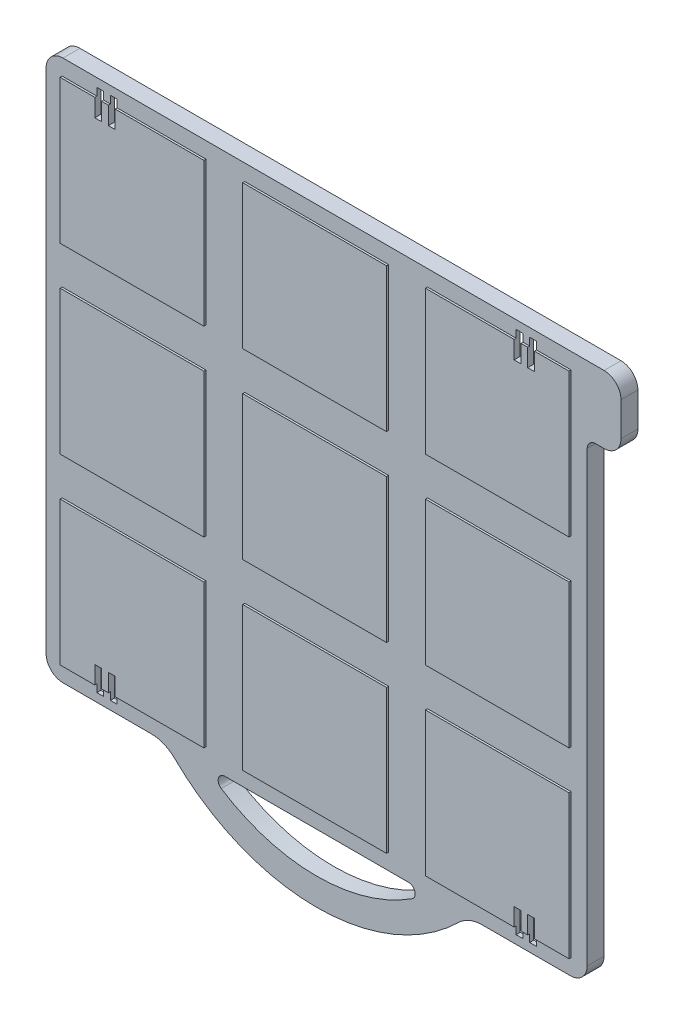
from build123d import *

# Parameters (mm, degrees)
BOSS_EXTRUDE1_DEPTH = 6.35
SHELL1_T            = -1.524
SKETCH2_W           = 53.975
SKETCH2_H           = 53.975
BOSS_EXTRUDE2_DEPTH = 0.762
SKETCH3_W           = 2.54
SKETCH3_H           = 9.525
CUT_EXTRUDE1_DEPTH  = 172.008977963
SKETCH4_R           = 6.2865
SKETCH4_R_2         = 4.7625
BOSS_EXTRUDE3_DEPTH = 4.826
RIB1_REACH          = 173.009
SKETCH5_WALLS_W     = 437.807455926
SKETCH5_WALLS_H     = 1.27
SKETCH5_WALLS_W_2   = 1.27
SKETCH5_WALLS_H_2   = 437.807455926


with BuildPart() as part:
    # Sketch1 → Boss-Extrude1 (new body)
    with BuildSketch(Plane.XY):
        with BuildLine():
            Line((101.6, 101.6), (107.95, 101.6))
            ThreePointArc((107.95, 101.6), (112.440128061, 99.740128061), (114.3, 95.25))
            Line((114.3, 95.25), (114.3, 82.55))
            ThreePointArc((114.3, 82.55), (112.440128061, 78.059871939), (107.95, 76.2))
            Line((107.95, 76.2), (104.775, 76.2))
            ThreePointArc((104.775, 76.2), (102.52993597, 75.27006403), (101.6, 73.025))
            Line((101.6, 73.025), (101.6, -95.25))
            ThreePointArc((101.6, -95.25), (99.740128061, -99.740128061), (95.25, -101.6))
            Line((95.25, -101.6), (62.217039467, -101.6))
            ThreePointArc((62.217039467, -101.6), (57.416890659, -102.542084733), (53.328890971, -105.228571429))
            ThreePointArc((53.328890971, -105.228571429), (0, -127), (-53.328890971, -105.228571429))
            ThreePointArc((-53.328890971, -105.228571429), (-57.416890659, -102.542084733), (-62.217039467, -101.6))
            Line((-62.217039467, -101.6), (-95.25, -101.6))
            ThreePointArc((-95.25, -101.6), (-99.740128061, -99.740128061), (-101.6, -95.25))
            Line((-101.6, -95.25), (-101.6, 95.25))
            ThreePointArc((-101.6, 95.25), (-99.740128061, 99.740128061), (-95.25, 101.6))
            Line((-95.25, 101.6), (101.6, 101.6))
        make_face()
        with BuildLine():
            Line((-34.454236314, -101.6), (34.454236314, -101.6))
            ThreePointArc((34.454236314, -101.6), (36.890518728, -103.42157951), (35.832405767, -106.2736))
            ThreePointArc((35.832405767, -106.2736), (0, -116.84), (-35.832405767, -106.2736))
            ThreePointArc((-35.832405767, -106.2736), (-36.890518728, -103.42157951), (-34.454236314, -101.6))
        make_face(mode=Mode.SUBTRACT)
    extrude(amount=BOSS_EXTRUDE1_DEPTH)

    # Shell1
    shell1_openings = [part.faces().sort_by_distance(p)[0] for p in [
        (0.794834734, -2.433656068, 0),
    ]]
    offset(amount=SHELL1_T, openings=shell1_openings, kind=Kind.INTERSECTION)

    # Sketch2 → Boss-Extrude2 (add)
    with BuildSketch(Plane.XY.offset(6.35)):
        with Locations((68.58, 0)):
            Rectangle(SKETCH2_W, SKETCH2_H)
        Rectangle(SKETCH2_W, SKETCH2_H)
        with Locations((68.58, 68.58)):
            Rectangle(SKETCH2_W, SKETCH2_H)
        with Locations((68.58, -68.58)):
            Rectangle(SKETCH2_W, SKETCH2_H)
        with Locations((0, -68.58)):
            Rectangle(SKETCH2_W, SKETCH2_H)
        with Locations((-68.58, -68.58)):
            Rectangle(SKETCH2_W, SKETCH2_H)
        with Locations((-68.58, 0)):
            Rectangle(SKETCH2_W, SKETCH2_H)
        with Locations((-68.58, 68.58)):
            Rectangle(SKETCH2_W, SKETCH2_H)
        with Locations((0, 68.58)):
            Rectangle(SKETCH2_W, SKETCH2_H)
    extrude(amount=BOSS_EXTRUDE2_DEPTH)

    # Sketch3 → Cut-Extrude1 (cut, through all)
    with BuildSketch(Plane.XY.offset(7.112)):
        with Locations((-81.28, 93.6625)):
            Rectangle(SKETCH3_W, SKETCH3_H)
        with Locations((-76.2, 93.6625)):
            Rectangle(SKETCH3_W, SKETCH3_H)
        with Locations((76.2, 93.6625)):
            Rectangle(SKETCH3_W, SKETCH3_H)
        with Locations((81.28, 93.6625)):
            Rectangle(SKETCH3_W, SKETCH3_H)
        with Locations((81.28, -93.6625)):
            Rectangle(SKETCH3_W, SKETCH3_H)
        with Locations((76.2, -93.6625)):
            Rectangle(SKETCH3_W, SKETCH3_H)
        with Locations((-76.2, -93.6625)):
            Rectangle(SKETCH3_W, SKETCH3_H)
        with Locations((-81.28, -93.6625)):
            Rectangle(SKETCH3_W, SKETCH3_H)
    extrude(amount=-CUT_EXTRUDE1_DEPTH, mode=Mode.SUBTRACT)

    # Sketch4 → Boss-Extrude3 (add)
    with BuildSketch(Plane(origin=(0, 0, 4.826), x_dir=(-1, 0, 0), z_dir=(0, 0, -1))):
        Circle(SKETCH4_R)
        Circle(SKETCH4_R_2, mode=Mode.SUBTRACT)
    extrude(amount=BOSS_EXTRUDE3_DEPTH)

    # Sketch5 walls → Rib1 (add, up to next)
    with BuildSketch(Plane(origin=(0, 0, 0), x_dir=(-1, 0, 0), z_dir=(0, 0, -1)), mode=Mode.PRIVATE) as rib1_sk1:
        with Locations((53.18125, 0)):
            Rectangle(SKETCH5_WALLS_W, SKETCH5_WALLS_H)
    rib1_tool1 = extrude(rib1_sk1.sketch, amount=-RIB1_REACH, mode=Mode.PRIVATE) - part.part
    # Sketch5 walls → Rib1 (add, up to next)
    with BuildSketch(Plane(origin=(0, 0, 0), x_dir=(-1, 0, 0), z_dir=(0, 0, -1)), mode=Mode.PRIVATE) as rib1_sk2:
        with Locations((-53.18125, 0)):
            Rectangle(SKETCH5_WALLS_W, SKETCH5_WALLS_H)
    rib1_tool2 = extrude(rib1_sk2.sketch, amount=-RIB1_REACH, mode=Mode.PRIVATE) - part.part
    # Sketch5 walls → Rib1 (add, up to next)
    with BuildSketch(Plane(origin=(0, 0, 0), x_dir=(-1, 0, 0), z_dir=(0, 0, -1)), mode=Mode.PRIVATE) as rib1_sk3:
        with Locations((0, -53.18125)):
            Rectangle(SKETCH5_WALLS_W_2, SKETCH5_WALLS_H_2)
    rib1_tool3 = extrude(rib1_sk3.sketch, amount=-RIB1_REACH, mode=Mode.PRIVATE) - part.part
    # Sketch5 walls → Rib1 (add, up to next)
    with BuildSketch(Plane(origin=(0, 0, 0), x_dir=(-1, 0, 0), z_dir=(0, 0, -1)), mode=Mode.PRIVATE) as rib1_sk4:
        with Locations((0, 53.18125)):
            Rectangle(SKETCH5_WALLS_W_2, SKETCH5_WALLS_H_2)
    rib1_tool4 = extrude(rib1_sk4.sketch, amount=-RIB1_REACH, mode=Mode.PRIVATE) - part.part
    # Sketch5 walls → Rib1 (add, up to next)
    with BuildSketch(Plane(origin=(0, 0, 0), x_dir=(-1, 0, 0), z_dir=(0, 0, -1)), mode=Mode.PRIVATE) as rib1_sk5:
        Polygon((-116.734475157, -117.632500769), (220.740224875, 219.842199263), (219.842199263, 220.740224875), (-117.632500769, -116.734475157), align=None)
    rib1_tool5 = extrude(rib1_sk5.sketch, amount=-RIB1_REACH, mode=Mode.PRIVATE) - part.part
    # Sketch5 walls → Rib1 (add, up to next)
    with BuildSketch(Plane(origin=(0, 0, 0), x_dir=(-1, 0, 0), z_dir=(0, 0, -1)), mode=Mode.PRIVATE) as rib1_sk6:
        Polygon((-117.632500769, 116.734475157), (219.842199263, -220.740224875), (220.740224875, -219.842199263), (-116.734475157, 117.632500769), align=None)
    rib1_tool6 = extrude(rib1_sk6.sketch, amount=-RIB1_REACH, mode=Mode.PRIVATE) - part.part
    # Sketch5 walls → Rib1 (add, up to next)
    with BuildSketch(Plane(origin=(0, 0, 0), x_dir=(-1, 0, 0), z_dir=(0, 0, -1)), mode=Mode.PRIVATE) as rib1_sk7:
        Polygon((116.734475157, 117.632500769), (-220.740224875, -219.842199263), (-219.842199263, -220.740224875), (117.632500769, 116.734475157), align=None)
    rib1_tool7 = extrude(rib1_sk7.sketch, amount=-RIB1_REACH, mode=Mode.PRIVATE) - part.part
    # Sketch5 walls → Rib1 (add, up to next)
    with BuildSketch(Plane(origin=(0, 0, 0), x_dir=(-1, 0, 0), z_dir=(0, 0, -1)), mode=Mode.PRIVATE) as rib1_sk8:
        Polygon((117.632500769, -116.734475157), (-221.255701937, 222.153727549), (-222.153727549, 221.255701937), (116.734475157, -117.632500769), align=None)
    rib1_tool8 = extrude(rib1_sk8.sketch, amount=-RIB1_REACH, mode=Mode.PRIVATE) - part.part
    add(rib1_tool1.solids().sort_by_distance((-53.18125, 0, 0))[0])
    add(rib1_tool2.solids().sort_by_distance((53.18125, 0, 0))[0])
    add(rib1_tool3.solids().sort_by_distance((0, -53.18125, 0))[0])
    add(rib1_tool4.solids().sort_by_distance((0, 53.18125, 0))[0])
    add(rib1_tool5.solids().sort_by_distance((-51.553862053, 51.553862053, 0))[0])
    add(rib1_tool6.solids().sort_by_distance((-51.553862053, -51.553862053, 0))[0])
    add(rib1_tool7.solids().sort_by_distance((51.553862053, -51.553862053, 0))[0])
    add(rib1_tool8.solids().sort_by_distance((52.26061339, 52.26061339, 0))[0])


solid = part.part
